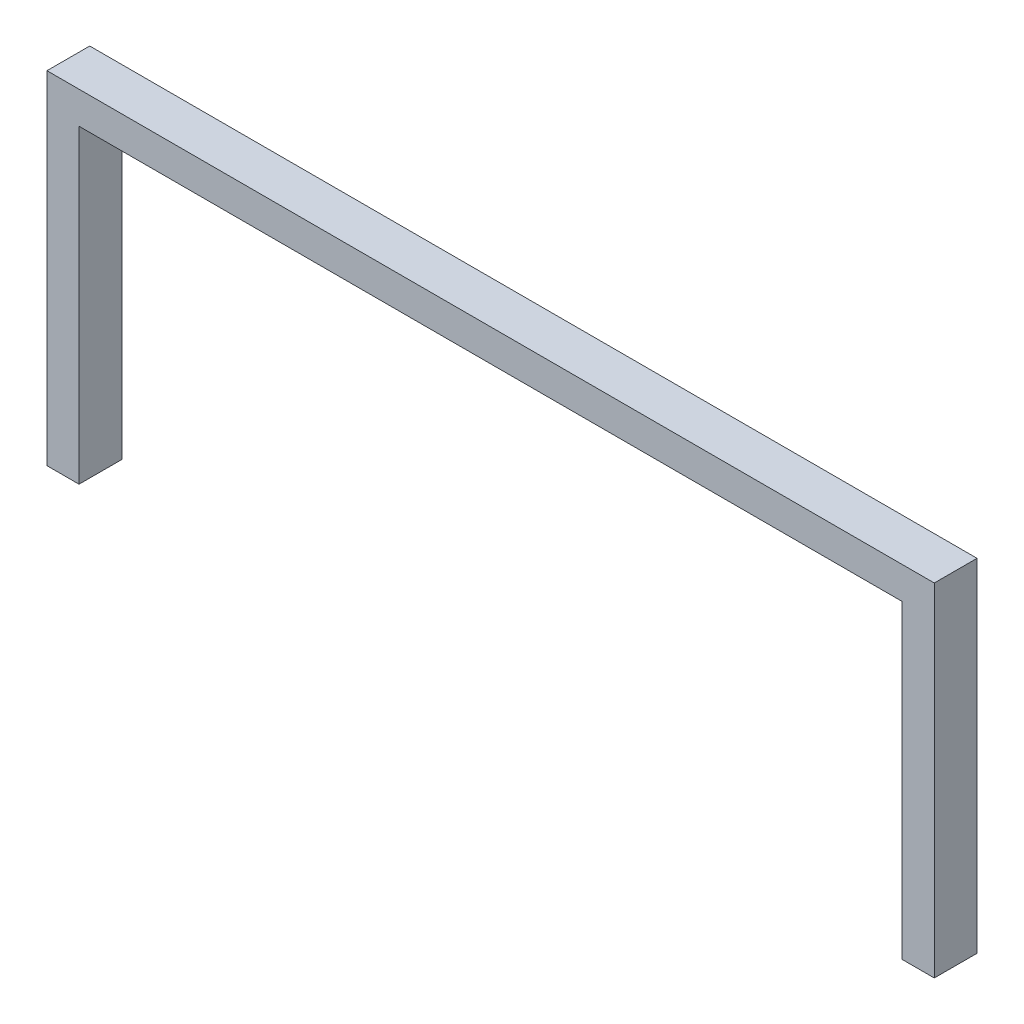
from build123d import *

# Parameters (mm, degrees)
BOSS_EXTRUDE1_DEPTH = 4


with BuildPart() as part:
    # Sketch1 → Boss-Extrude1 (new body)
    with BuildSketch(Plane.XY):
        Polygon((0, 0), (-3, 0), (-3, 32), (80, 32), (80, 0), (77, 0), (77, 29), (0, 29), align=None)
    extrude(amount=BOSS_EXTRUDE1_DEPTH)


solid = part.part
